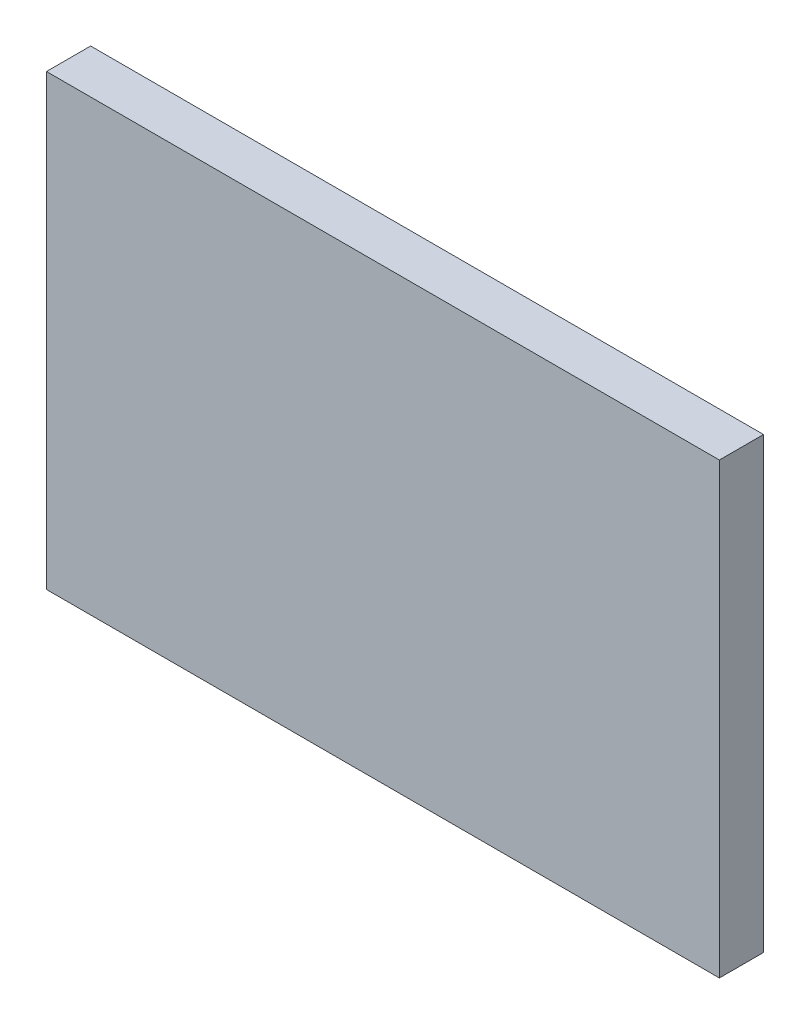
from build123d import *

# Parameters (mm, degrees)
SKETCH1_W               = 15.24
SKETCH1_H               = 10.16
COMPONENT_OUTLINE_DEPTH = 1


with BuildPart() as part:
    # Sketch1 → Component_Outline (new body)
    with BuildSketch(Plane.XY):
        Rectangle(SKETCH1_W, SKETCH1_H)
    extrude(amount=COMPONENT_OUTLINE_DEPTH)


solid = part.part
